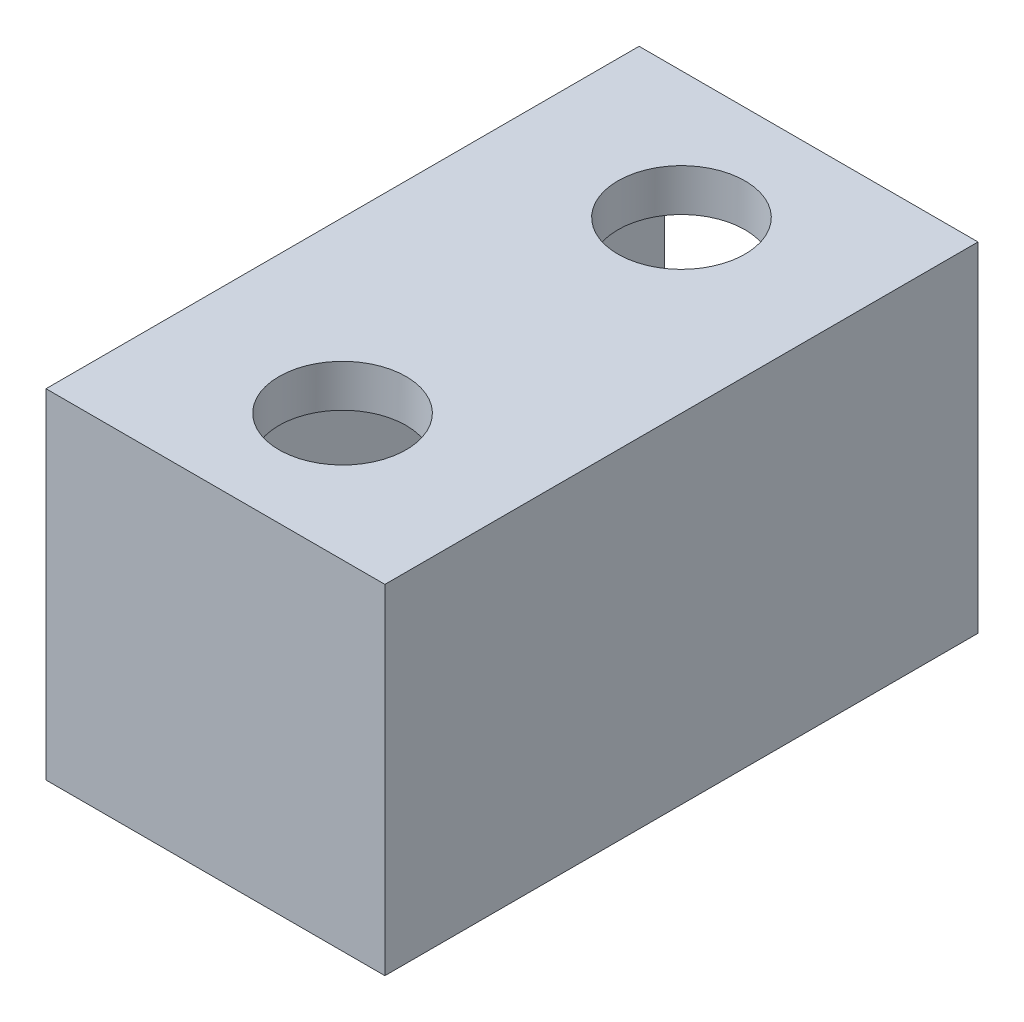
from build123d import *

# Parameters (mm, degrees)
SKETCH1_W           = 40
SKETCH1_H           = 40
SKETCH1_W_2         = 34
SKETCH1_H_2         = 34
BOSS_EXTRUDE1_DEPTH = 70
SKETCH2_W           = 34
SKETCH2_H           = 3
BOSS_EXTRUDE2_DEPTH = 37
CUT_EXTRUDE1_DEPTH  = 37
SKETCH4_R           = 8.5
SKETCH4_R_2         = 7.5
BOSS_EXTRUDE3_DEPTH = 2
SKETCH6_R           = 7.5
BOSS_EXTRUDE4_DEPTH = 10
FILLET2_R           = 1.5
FILLET3_R           = 1.5
FILLET4_R           = 1.5
FILLET5_R           = 1.5


with BuildPart() as part:
    # Sketch1 → Boss-Extrude1 (new body)
    with BuildSketch(Plane.XY):
        with Locations((-20, 20)):
            Rectangle(SKETCH1_W, SKETCH1_H)
        with Locations((-20, 20)):
            Rectangle(SKETCH1_W_2, SKETCH1_H_2, mode=Mode.SUBTRACT)
    extrude(amount=BOSS_EXTRUDE1_DEPTH)

    # Sketch2 → Boss-Extrude2 (add)
    with BuildSketch(Plane(origin=(0, 37, 0), x_dir=(-1, 0, 0), z_dir=(0, -1, 0))):
        with Locations((20, -68.5)):
            Rectangle(SKETCH2_W, SKETCH2_H)
    extrude(amount=BOSS_EXTRUDE2_DEPTH)

    # Sketch3 → Cut-Extrude1 (cut)
    with BuildSketch(Plane(origin=(0, 40, 0), x_dir=(1, 0, 0), z_dir=(0, 1, 0))):
        with BuildLine():
            ThreePointArc((-12.5, -15), (-14.696699141, -9.696699141), (-20, -7.5))
            Line((-20, -7.5), (-20, -15))
            Line((-20, -15), (-12.5, -15))
        make_face()
        with BuildLine():
            Line((-20, -15), (-20, -7.5))
            ThreePointArc((-20, -7.5), (-25.303300859, -9.696699141), (-27.5, -15))
            Line((-27.5, -15), (-20, -15))
        make_face()
        with BuildLine():
            Line((-12.5, -15), (-20, -15))
            Line((-20, -15), (-20, -22.5))
            ThreePointArc((-20, -22.5), (-14.696699141, -20.303300859), (-12.5, -15))
        make_face()
        with BuildLine():
            Line((-20, -22.5), (-20, -15))
            Line((-20, -15), (-27.5, -15))
            ThreePointArc((-27.5, -15), (-25.303300859, -20.303300859), (-20, -22.5))
        make_face()
        with BuildLine():
            ThreePointArc((-12.5, -55), (-14.696699141, -49.696699141), (-20, -47.5))
            Line((-20, -47.5), (-20, -55))
            Line((-20, -55), (-12.5, -55))
        make_face()
        with BuildLine():
            Line((-20, -55), (-20, -47.5))
            ThreePointArc((-20, -47.5), (-25.303300859, -49.696699141), (-27.5, -55))
            Line((-27.5, -55), (-20, -55))
        make_face()
        with BuildLine():
            Line((-12.5, -55), (-20, -55))
            Line((-20, -55), (-20, -62.5))
            ThreePointArc((-20, -62.5), (-14.696699141, -60.303300859), (-12.5, -55))
        make_face()
        with BuildLine():
            Line((-20, -62.5), (-20, -55))
            Line((-20, -55), (-27.5, -55))
            ThreePointArc((-27.5, -55), (-25.303300859, -60.303300859), (-20, -62.5))
        make_face()
    extrude(amount=-CUT_EXTRUDE1_DEPTH, mode=Mode.SUBTRACT)

    # Sketch4 → Boss-Extrude3 (add)
    with BuildSketch(Plane(origin=(0, 37, 0), x_dir=(-1, 0, 0), z_dir=(0, -1, 0))):
        with Locations((20, -15)):
            Circle(SKETCH4_R)
        with Locations((20, -15)):
            Circle(SKETCH4_R_2, mode=Mode.SUBTRACT)
        with Locations((20, -55)):
            Circle(SKETCH4_R)
        with Locations((20, -55)):
            Circle(SKETCH4_R_2, mode=Mode.SUBTRACT)
    extrude(amount=BOSS_EXTRUDE3_DEPTH)

    # Sketch6 → Boss-Extrude4 (add)
    with BuildSketch(Plane(origin=(0, 3, 0), x_dir=(1, 0, 0), z_dir=(0, 1, 0))):
        with Locations((-20, -15)):
            Circle(SKETCH6_R)
        with Locations((-20, -55)):
            Circle(SKETCH6_R)
    extrude(amount=-BOSS_EXTRUDE4_DEPTH)

    # Fillet2
    fillet2_edges = [part.edges().sort_by_distance(p)[0] for p in [
        (-27.5, -7, 55),
    ]]
    fillet(fillet2_edges, radius=FILLET2_R)

    # Fillet3
    fillet3_edges = [part.edges().sort_by_distance(p)[0] for p in [
        (-27.5, -7, 15),
    ]]
    fillet(fillet3_edges, radius=FILLET3_R)

    # Fillet4
    fillet4_edges = [part.edges().sort_by_distance(p)[0] for p in [
        (-27.5, 0, 15),
    ]]
    fillet(fillet4_edges, radius=FILLET4_R)

    # Fillet5
    fillet5_edges = [part.edges().sort_by_distance(p)[0] for p in [
        (-27.5, 0, 55),
    ]]
    fillet(fillet5_edges, radius=FILLET5_R)


solid = part.part
